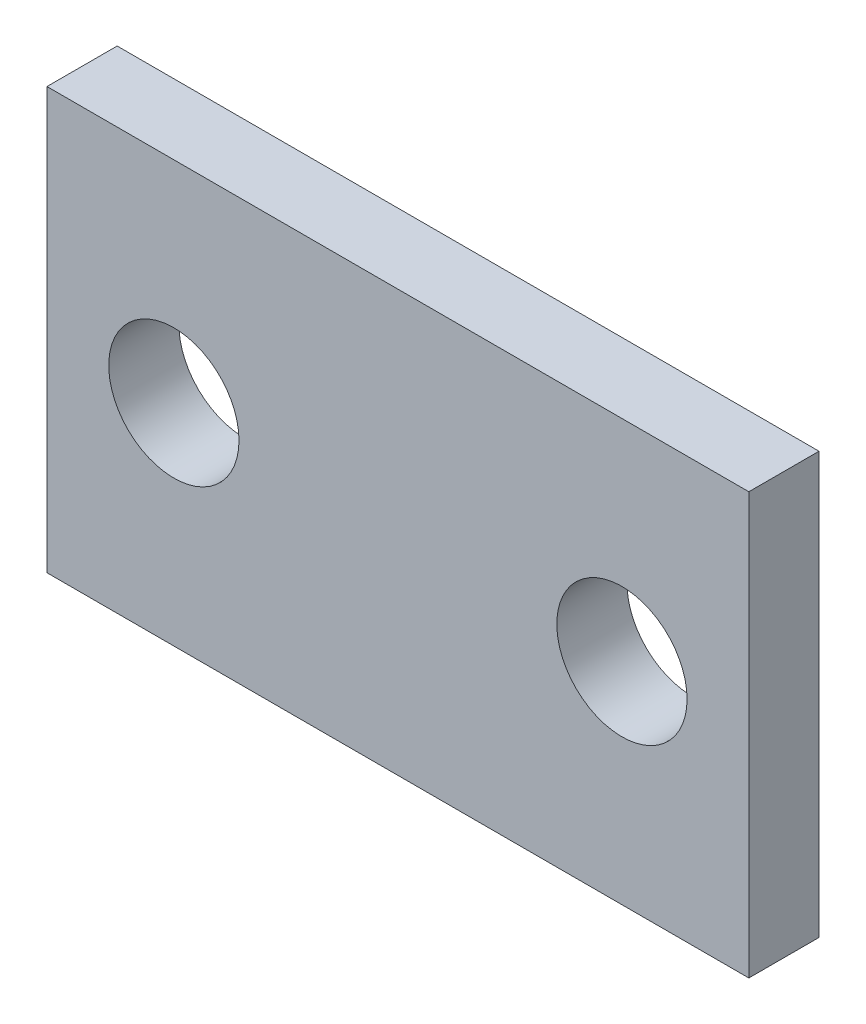
from build123d import *

# Parameters (mm, degrees)
SKETCH1_W                 = 15.875
SKETCH1_H                 = 9.525
BOSS_EXTRUDE1_DEPTH       = 1.5875
F_4_CLEARANCE_HOLE1_D     = 2.9464
F_4_CLEARANCE_HOLE1_DEPTH = 1.5875


with BuildPart() as part:
    # Sketch1 → Boss-Extrude1 (new body)
    with BuildSketch(Plane.XY):
        Rectangle(SKETCH1_W, SKETCH1_H)
    extrude(amount=BOSS_EXTRUDE1_DEPTH)

    # #4 Clearance Hole1
    with Locations(Plane.XY.offset(1.5875)):
        with Locations((-5.0673, 0), (5.0673, 0)):
            Hole(F_4_CLEARANCE_HOLE1_D / 2, depth=F_4_CLEARANCE_HOLE1_DEPTH)


solid = part.part
